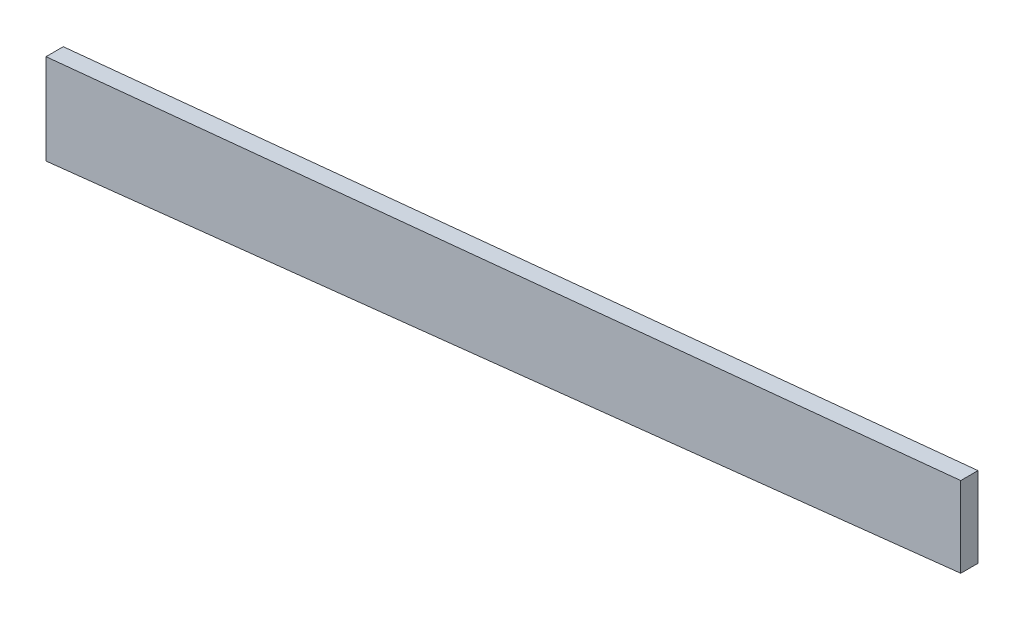
from build123d import *

# Parameters (mm, degrees)
BOSS_EXTRUDE1_DEPTH = 3.175


with BuildPart() as part:
    # Sketch1 → Boss-Extrude1 (new body)
    with BuildSketch(Plane.XY):
        Polygon((-169.8625, 105.890608705), (-169.8625, 122.519845253), (-1.5875, 139.127114934), (-1.5875, 124.350207241), align=None)
    extrude(amount=-BOSS_EXTRUDE1_DEPTH)


solid = part.part
